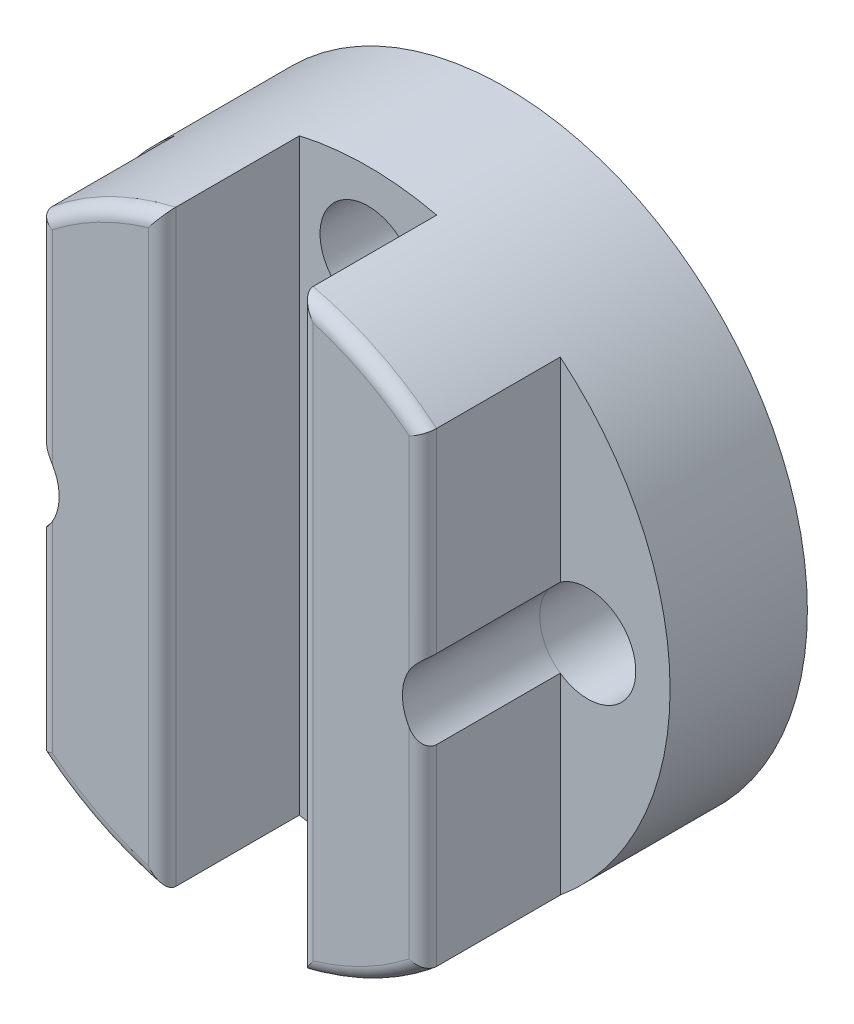
from build123d import *

# Parameters (mm, degrees)
ESQUISSE1_R             = 11
BOSS_EXTRU_1_DEPTH      = 5
BOSS_EXTRU_3_DEPTH      = 5
CONG_3_R                = 0.5
ESQUISSE3D1_R           = 1.05
ENL_V_MAT_EXTRU_1_DEPTH = 25.164275332
ESQUISSE3D2_R           = 1.75
ENL_V_MAT_EXTRU_2_DEPTH = 2.5
ESQUISSE4_R             = 1.75
ENL_V_MAT_EXTRU_3_DEPTH = 17.340134669


with BuildPart() as part:
    # Esquisse1 → Boss.-Extru.1 (new body)
    with BuildSketch(Plane.XY):
        Circle(ESQUISSE1_R)
    extrude(amount=BOSS_EXTRU_1_DEPTH)

    # Esquisse2 → Boss.-Extru.3 (add)
    with BuildSketch(Plane.XY.offset(5)):
        with BuildLine():
            ThreePointArc((-2.5, 10.712142643), (-4.878752687, 9.858893053), (-7, 8.485281374))
            Line((-7, 8.485281374), (-7, -8.485281374))
            ThreePointArc((-7, -8.485281374), (-4.878752687, -9.858893053), (-2.5, -10.712142643))
            Line((-2.5, -10.712142643), (-2.5, 10.712142643))
        make_face()
        with BuildLine():
            ThreePointArc((7, 8.485281374), (4.878752687, 9.858893053), (2.5, 10.712142643))
            Line((2.5, 10.712142643), (2.5, -10.712142643))
            ThreePointArc((2.5, -10.712142643), (4.878752687, -9.858893053), (7, -8.485281374))
            Line((7, -8.485281374), (7, 8.485281374))
        make_face()
    extrude(amount=BOSS_EXTRU_3_DEPTH)

    # Congé3
    cong_3_edges = [part.edges().sort_by_distance(p)[0] for p in [
        (4.878752687, 9.858893053, 10),
        (4.878752687, -9.858893053, 10),
        (7, 0, 10),
        (2.5, 0, 10),
        (-4.878752687, 9.858893053, 10),
        (-4.878752687, -9.858893053, 10),
        (-2.5, 0, 10),
        (-7, 0, 10),
    ]]
    fillet(cong_3_edges, radius=CONG_3_R)

    # Esquisse3D1 → Enlèv. mat.-Extru.1 (cut, through all)
    with BuildSketch(Plane(origin=(0.000157277, -8.050163785, 0), x_dir=(0, 1, 0), z_dir=(0, 0, -1))):
        with Locations(Location((0, 0, 0), (0, 0, 90))):
            Circle(ESQUISSE3D1_R)
        with Locations(Location((8, 8, 0), (0, 0, 90))):
            Circle(ESQUISSE3D1_R)
        with Locations(Location((16, 0, 0), (0, 0, 90))):
            Circle(ESQUISSE3D1_R)
        with Locations(Location((8, -8, 0), (0, 0, 90))):
            Circle(ESQUISSE3D1_R)
    extrude(amount=-ENL_V_MAT_EXTRU_1_DEPTH, mode=Mode.SUBTRACT)

    # Esquisse3D2 → Enlèv. mat.-Extru.2 (cut)
    with BuildSketch(Plane(origin=(-8, 0, 5), x_dir=(0.9999950851821525, -0.0031352211308848022, 0), z_dir=(0, 0, 1))):
        with Locations(Location((0, 0, 0), (0, 0, 305.029539812))):
            Circle(ESQUISSE3D2_R)
        with Locations(Location((8.075049898, -7.974722127, 0), (0, 0, 0.179635233))):
            Circle(ESQUISSE3D2_R)
        with Locations(Location((7.974878912, 8.025042451, 0), (0, 0, 0.179635233))):
            Circle(ESQUISSE3D2_R)
        with Locations(Location((16.000078637, 0, 0), (0, 0, 235.329730654))):
            Circle(ESQUISSE3D2_R)
    extrude(amount=-ENL_V_MAT_EXTRU_2_DEPTH, mode=Mode.SUBTRACT)

    # Esquisse4 → Enlèv. mat.-Extru.3 (cut, through all)
    with BuildSketch(Plane.XY.offset(5)):
        with Locations((-7.999842723, -0.050163785)):
            Circle(ESQUISSE4_R)
        with Locations((8.000157277, -0.050163785)):
            Circle(ESQUISSE4_R)
    extrude(amount=ENL_V_MAT_EXTRU_3_DEPTH, mode=Mode.SUBTRACT)


solid = part.part
